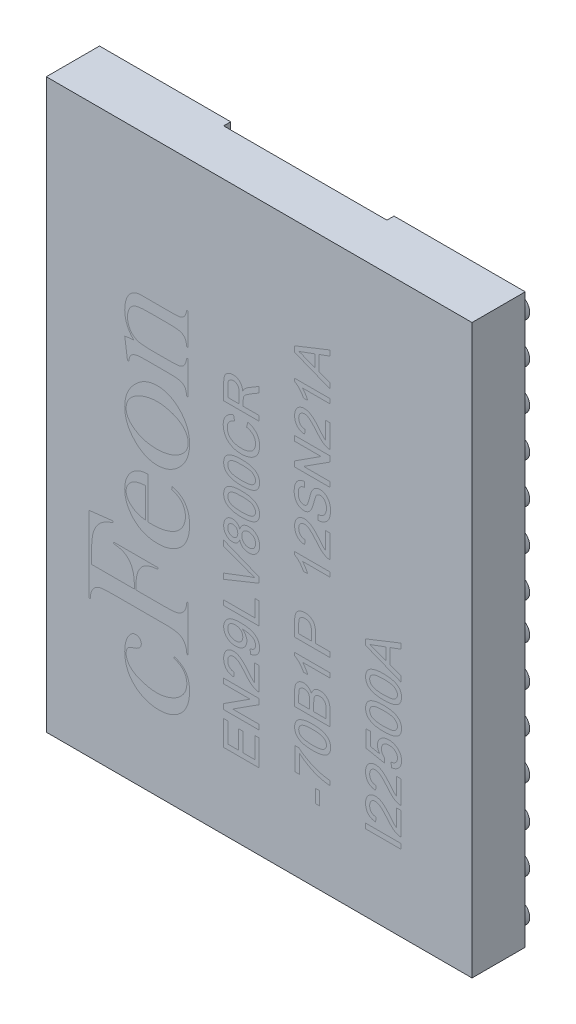
from build123d import *

# Parameters (mm, degrees)
SKETCH_1_W          = 6
SKETCH_1_H          = 8
EXTRUDE_1_DEPTH     = 0.75
SKETCH_2_R          = 0.154
EXTRUDE_2_DEPTH     = 0.1
SKETCH_5_W          = 2.301072574
SKETCH_5_H          = 0.785
CUT_EXTRUDE_3_DEPTH = 0.1
SKETCH_3_W          = 2.301072574
SKETCH_3_H          = 6.43
CUT_EXTRUDE_2_DEPTH = 0.07


with BuildPart() as part:
    # Эскиз1 → Бобышка-Вытянуть1 (new body)
    with BuildSketch(Plane.XY):
        Rectangle(SKETCH_1_W, SKETCH_1_H)
    extrude(amount=EXTRUDE_1_DEPTH)

    # Эскиз2 → Бобышка-Вытянуть2 (add)
    with BuildSketch(Plane(origin=(0, 0, 0), x_dir=(-1, 0, 0), z_dir=(0, 0, -1))):
        with Locations((2.809043524, 3.68)):
            Circle(SKETCH_2_R)
        with Locations((2.809043524, 3.11)):
            Circle(SKETCH_2_R)
        with Locations((2.809043524, 2.54)):
            Circle(SKETCH_2_R)
        with Locations((2.809043524, 1.97)):
            Circle(SKETCH_2_R)
        with Locations((2.809043524, 1.4)):
            Circle(SKETCH_2_R)
        with Locations((2.809043524, 0.83)):
            Circle(SKETCH_2_R)
        with Locations((2.809043524, 0.26)):
            Circle(SKETCH_2_R)
        with Locations((2.359043524, 3.11)):
            Circle(SKETCH_2_R)
        with Locations((2.359043524, 2.54)):
            Circle(SKETCH_2_R)
        with Locations((2.359043524, 1.97)):
            Circle(SKETCH_2_R)
        with Locations((2.359043524, 1.4)):
            Circle(SKETCH_2_R)
        with Locations((2.359043524, 0.83)):
            Circle(SKETCH_2_R)
        with Locations((2.359043524, 0.26)):
            Circle(SKETCH_2_R)
        with Locations((1.909043524, 3.11)):
            Circle(SKETCH_2_R)
        with Locations((1.909043524, 2.54)):
            Circle(SKETCH_2_R)
        with Locations((1.909043524, 1.97)):
            Circle(SKETCH_2_R)
        with Locations((1.909043524, 1.4)):
            Circle(SKETCH_2_R)
        with Locations((1.909043524, 0.83)):
            Circle(SKETCH_2_R)
        with Locations((1.909043524, 0.26)):
            Circle(SKETCH_2_R)
        with Locations((1.459043524, 3.11)):
            Circle(SKETCH_2_R)
        with Locations((1.459043524, 2.54)):
            Circle(SKETCH_2_R)
        with Locations((1.459043524, 1.97)):
            Circle(SKETCH_2_R)
        with Locations((1.459043524, 1.4)):
            Circle(SKETCH_2_R)
        with Locations((1.459043524, 0.83)):
            Circle(SKETCH_2_R)
        with Locations((1.459043524, 0.26)):
            Circle(SKETCH_2_R)
        with Locations((2.359043524, 3.68)):
            Circle(SKETCH_2_R)
        with Locations((1.909043524, 3.68)):
            Circle(SKETCH_2_R)
        with Locations((1.459043524, 3.68)):
            Circle(SKETCH_2_R)
        with Locations((1.459043524, -3.68)):
            Circle(SKETCH_2_R)
        with Locations((1.909043524, -3.68)):
            Circle(SKETCH_2_R)
        with Locations((2.359043524, -3.68)):
            Circle(SKETCH_2_R)
        with Locations((1.459043524, -0.26)):
            Circle(SKETCH_2_R)
        with Locations((1.459043524, -0.83)):
            Circle(SKETCH_2_R)
        with Locations((1.459043524, -1.4)):
            Circle(SKETCH_2_R)
        with Locations((1.459043524, -1.97)):
            Circle(SKETCH_2_R)
        with Locations((1.459043524, -2.54)):
            Circle(SKETCH_2_R)
        with Locations((1.459043524, -3.11)):
            Circle(SKETCH_2_R)
        with Locations((1.909043524, -0.26)):
            Circle(SKETCH_2_R)
        with Locations((1.909043524, -0.83)):
            Circle(SKETCH_2_R)
        with Locations((1.909043524, -1.4)):
            Circle(SKETCH_2_R)
        with Locations((1.909043524, -1.97)):
            Circle(SKETCH_2_R)
        with Locations((1.909043524, -2.54)):
            Circle(SKETCH_2_R)
        with Locations((1.909043524, -3.11)):
            Circle(SKETCH_2_R)
        with Locations((2.359043524, -0.26)):
            Circle(SKETCH_2_R)
        with Locations((2.359043524, -0.83)):
            Circle(SKETCH_2_R)
        with Locations((2.359043524, -1.4)):
            Circle(SKETCH_2_R)
        with Locations((2.359043524, -1.97)):
            Circle(SKETCH_2_R)
        with Locations((2.359043524, -2.54)):
            Circle(SKETCH_2_R)
        with Locations((2.359043524, -3.11)):
            Circle(SKETCH_2_R)
        with Locations((2.809043524, -0.26)):
            Circle(SKETCH_2_R)
        with Locations((2.809043524, -0.83)):
            Circle(SKETCH_2_R)
        with Locations((2.809043524, -1.4)):
            Circle(SKETCH_2_R)
        with Locations((2.809043524, -1.97)):
            Circle(SKETCH_2_R)
        with Locations((2.809043524, -2.54)):
            Circle(SKETCH_2_R)
        with Locations((2.809043524, -3.11)):
            Circle(SKETCH_2_R)
        with Locations((-2.809043524, -3.11)):
            Circle(SKETCH_2_R)
        with Locations((-2.809043524, -2.54)):
            Circle(SKETCH_2_R)
        with Locations((-2.809043524, -1.97)):
            Circle(SKETCH_2_R)
        with Locations((-2.809043524, -1.4)):
            Circle(SKETCH_2_R)
        with Locations((-2.809043524, -0.83)):
            Circle(SKETCH_2_R)
        with Locations((-2.809043524, -0.26)):
            Circle(SKETCH_2_R)
        with Locations((-2.359043524, -3.11)):
            Circle(SKETCH_2_R)
        with Locations((-2.359043524, -2.54)):
            Circle(SKETCH_2_R)
        with Locations((-2.359043524, -1.97)):
            Circle(SKETCH_2_R)
        with Locations((-2.359043524, -1.4)):
            Circle(SKETCH_2_R)
        with Locations((-2.359043524, -0.83)):
            Circle(SKETCH_2_R)
        with Locations((-2.359043524, -0.26)):
            Circle(SKETCH_2_R)
        with Locations((-1.909043524, -3.11)):
            Circle(SKETCH_2_R)
        with Locations((-1.909043524, -2.54)):
            Circle(SKETCH_2_R)
        with Locations((-1.909043524, -1.97)):
            Circle(SKETCH_2_R)
        with Locations((-1.909043524, -1.4)):
            Circle(SKETCH_2_R)
        with Locations((-1.909043524, -0.83)):
            Circle(SKETCH_2_R)
        with Locations((-1.909043524, -0.26)):
            Circle(SKETCH_2_R)
        with Locations((-1.459043524, -3.11)):
            Circle(SKETCH_2_R)
        with Locations((-1.459043524, -2.54)):
            Circle(SKETCH_2_R)
        with Locations((-1.459043524, -1.97)):
            Circle(SKETCH_2_R)
        with Locations((-1.459043524, -1.4)):
            Circle(SKETCH_2_R)
        with Locations((-1.459043524, -0.83)):
            Circle(SKETCH_2_R)
        with Locations((-1.459043524, -0.26)):
            Circle(SKETCH_2_R)
        with Locations((-2.359043524, -3.68)):
            Circle(SKETCH_2_R)
        with Locations((-1.909043524, -3.68)):
            Circle(SKETCH_2_R)
        with Locations((-1.459043524, -3.68)):
            Circle(SKETCH_2_R)
        with Locations((-1.459043524, 3.68)):
            Circle(SKETCH_2_R)
        with Locations((-1.909043524, 3.68)):
            Circle(SKETCH_2_R)
        with Locations((-2.359043524, 3.68)):
            Circle(SKETCH_2_R)
        with Locations((-1.459043524, 0.26)):
            Circle(SKETCH_2_R)
        with Locations((-1.459043524, 0.83)):
            Circle(SKETCH_2_R)
        with Locations((-1.459043524, 1.4)):
            Circle(SKETCH_2_R)
        with Locations((-1.459043524, 1.97)):
            Circle(SKETCH_2_R)
        with Locations((-1.459043524, 2.54)):
            Circle(SKETCH_2_R)
        with Locations((-1.459043524, 3.11)):
            Circle(SKETCH_2_R)
        with Locations((-1.909043524, 0.26)):
            Circle(SKETCH_2_R)
        with Locations((-1.909043524, 0.83)):
            Circle(SKETCH_2_R)
        with Locations((-1.909043524, 1.4)):
            Circle(SKETCH_2_R)
        with Locations((-1.909043524, 1.97)):
            Circle(SKETCH_2_R)
        with Locations((-1.909043524, 2.54)):
            Circle(SKETCH_2_R)
        with Locations((-1.909043524, 3.11)):
            Circle(SKETCH_2_R)
        with Locations((-2.359043524, 0.26)):
            Circle(SKETCH_2_R)
        with Locations((-2.359043524, 0.83)):
            Circle(SKETCH_2_R)
        with Locations((-2.359043524, 1.4)):
            Circle(SKETCH_2_R)
        with Locations((-2.359043524, 1.97)):
            Circle(SKETCH_2_R)
        with Locations((-2.359043524, 2.54)):
            Circle(SKETCH_2_R)
        with Locations((-2.359043524, 3.11)):
            Circle(SKETCH_2_R)
        with Locations((-2.809043524, 0.26)):
            Circle(SKETCH_2_R)
        with Locations((-2.809043524, 0.83)):
            Circle(SKETCH_2_R)
        with Locations((-2.809043524, 1.4)):
            Circle(SKETCH_2_R)
        with Locations((-2.809043524, 1.97)):
            Circle(SKETCH_2_R)
        with Locations((-2.809043524, 2.54)):
            Circle(SKETCH_2_R)
        with Locations((-2.809043524, 3.11)):
            Circle(SKETCH_2_R)
        with Locations((-2.809043524, 3.68)):
            Circle(SKETCH_2_R)
        with Locations((-2.809043524, -3.705)):
            Circle(SKETCH_2_R)
    extrude(amount=EXTRUDE_2_DEPTH)

    # Эскиз5 → Вырез-Вытянуть3 (cut)
    with BuildSketch(Plane(origin=(0, 0, 0), x_dir=(-1, 0, 0), z_dir=(0, 0, -1))):
        with Locations((0, 3.6075)):
            Rectangle(SKETCH_5_W, SKETCH_5_H)
        with Locations((0, -3.6075)):
            Rectangle(SKETCH_5_W, SKETCH_5_H)
    extrude(amount=-CUT_EXTRUDE_3_DEPTH, mode=Mode.SUBTRACT)

    # Эскиз3 → Вырез-Вытянуть2 (cut)
    with BuildSketch(Plane(origin=(0, 0, 0), x_dir=(-1, 0, 0), z_dir=(0, 0, -1))):
        Rectangle(SKETCH_3_W, SKETCH_3_H)
    extrude(amount=-CUT_EXTRUDE_2_DEPTH, mode=Mode.SUBTRACT)


solid = part.part
